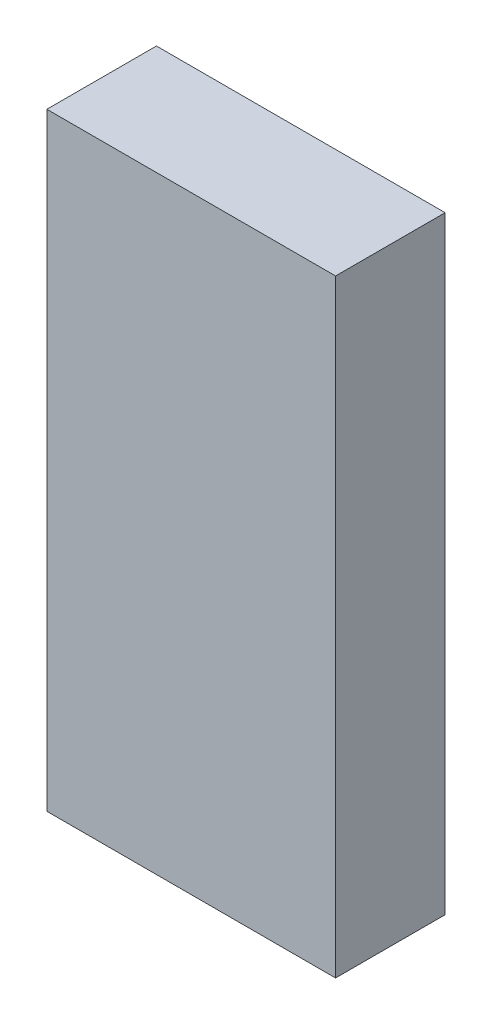
from build123d import *

# Parameters (mm, degrees)
SKETCH1_W           = 16.732266826
SKETCH1_H           = 35.23627451
BOSS_EXTRUDE1_DEPTH = 6.35


with BuildPart() as part:
    # Sketch1 → Boss-Extrude1 (new body)
    with BuildSketch(Plane.XY):
        with Locations((8.366133413, -17.618137255)):
            Rectangle(SKETCH1_W, SKETCH1_H)
    extrude(amount=BOSS_EXTRUDE1_DEPTH)


solid = part.part
